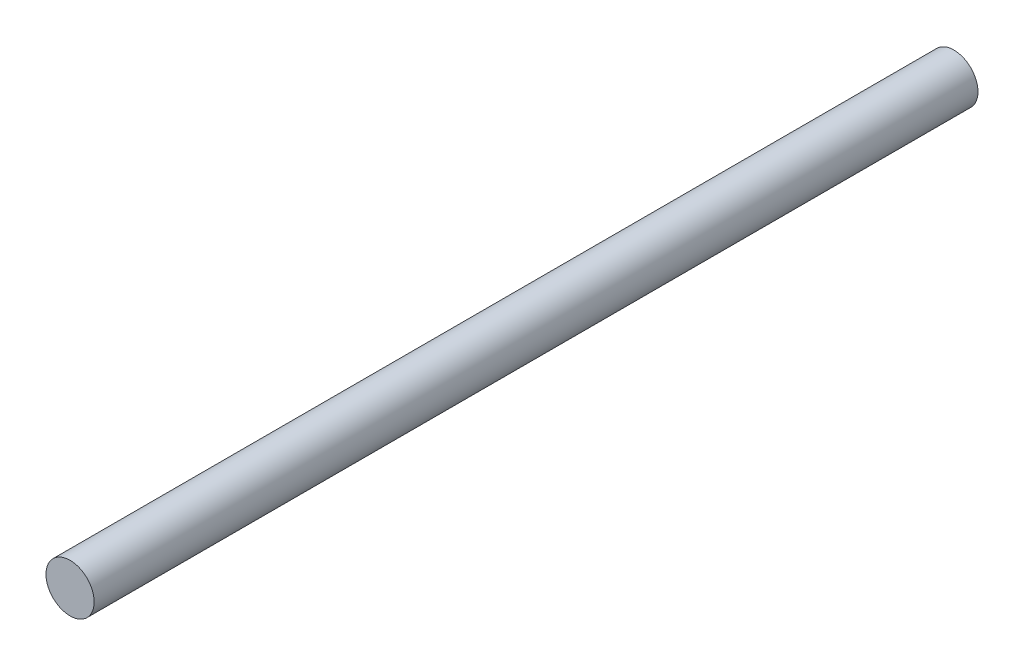
from build123d import *

# Parameters (mm, degrees)
SKETCH1_R           = 3
BOSS_EXTRUDE1_DEPTH = 110


with BuildPart() as part:
    # Sketch1 → Boss-Extrude1 (new body)
    with BuildSketch(Plane.XY):
        with Locations((-55.404136253, 33.650364964)):
            Circle(SKETCH1_R)
    extrude(amount=BOSS_EXTRUDE1_DEPTH)


solid = part.part
